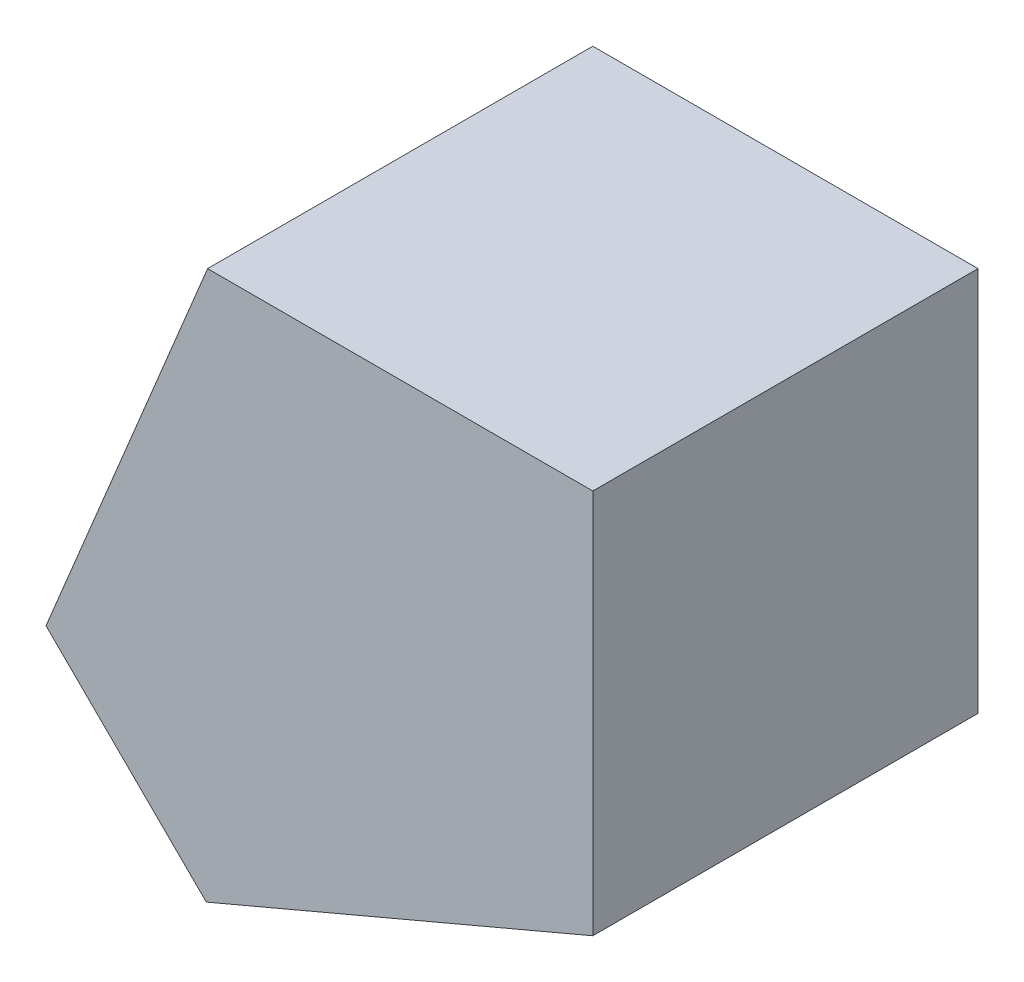
from build123d import *

# Parameters (mm, degrees)
EXTRUDE_1_DEPTH = 5


with BuildPart() as part:
    # 草图1 → 凸台-拉伸1 (new body)
    with BuildSketch(Plane.XY):
        Polygon((16.624762525, 11.247123494), (16.624762525, 16.247123494), (11.624762525, 16.247123494), (9.527288384, 11.183372976), (11.608011074, 9.117638844), align=None)
    extrude(amount=EXTRUDE_1_DEPTH)


solid = part.part
